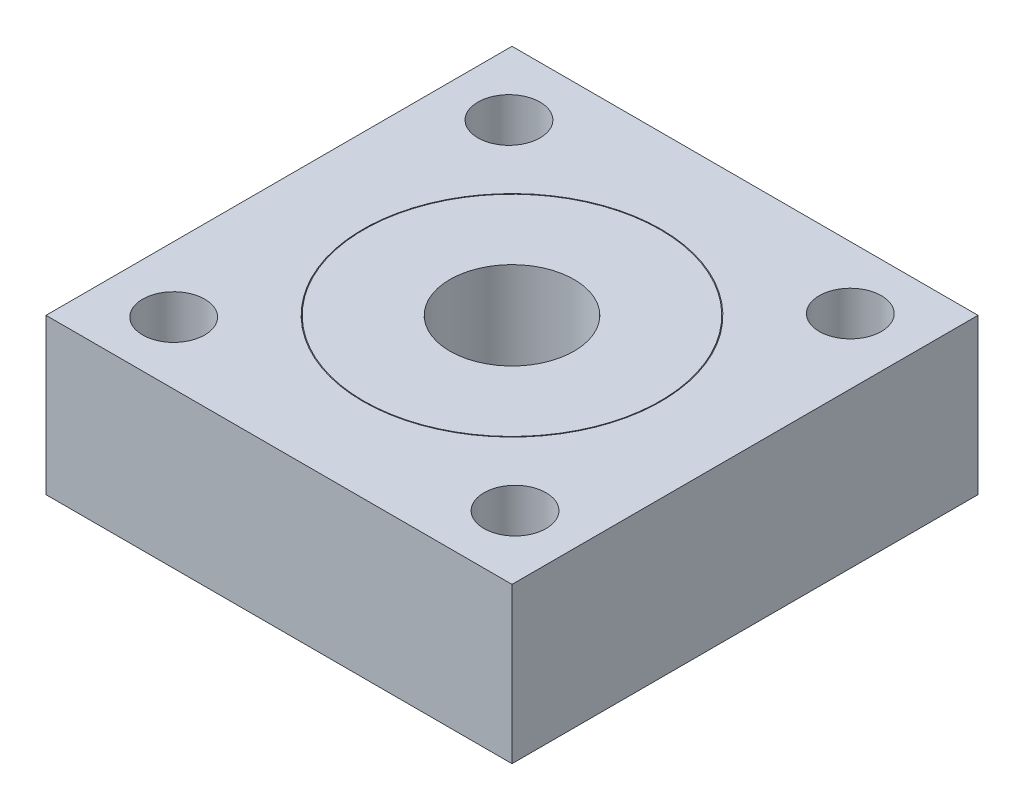
from build123d import *

# Parameters (mm, degrees)
SKETCH1_W           = 30
SKETCH1_H           = 30
BOSS_EXTRUDE1_DEPTH = 10
SKETCH2_R           = 9.6
SKETCH2_R_2         = 9.55
CUT_EXTRUDE1_DEPTH  = 7
SKETCH3_R           = 4
CUT_EXTRUDE2_DEPTH  = 7
SKETCH4_R           = 2
CUT_EXTRUDE3_DEPTH  = 10
CIRPATTERN1_COUNT   = 4


with BuildPart() as part:
    # Sketch1 → Boss-Extrude1 (new body)
    with BuildSketch(Plane(origin=(0, 0, 0), x_dir=(1, 0, 0), z_dir=(0, 1, 0))):
        Rectangle(SKETCH1_W, SKETCH1_H)
    extrude(amount=BOSS_EXTRUDE1_DEPTH)

    # Sketch2 → Cut-Extrude1 (cut)
    with BuildSketch(Plane(origin=(0, 10, 0), x_dir=(1, 0, 0), z_dir=(0, 1, 0))):
        Circle(SKETCH2_R)
        Circle(SKETCH2_R_2, mode=Mode.SUBTRACT)
    extrude(amount=-CUT_EXTRUDE1_DEPTH, mode=Mode.SUBTRACT)

    # Sketch3 → Cut-Extrude2 (cut)
    with BuildSketch(Plane(origin=(0, 10, 0), x_dir=(1, 0, 0), z_dir=(0, 1, 0))):
        Circle(SKETCH3_R)
    extrude(amount=-CUT_EXTRUDE2_DEPTH, mode=Mode.SUBTRACT)

    # Sketch4 → Cut-Extrude3 (cut)
    with BuildSketch(Plane(origin=(0, 10, 0), x_dir=(1, 0, 0), z_dir=(0, 1, 0))):
        with Locations((10.792349727, 10.987509758)):
            Circle(SKETCH4_R)
    cut_extrude3 = extrude(amount=-CUT_EXTRUDE3_DEPTH, mode=Mode.SUBTRACT)

    # CirPattern1: Cut-Extrude3 ×4 about axis
    cirpattern1_axis = Axis((0, 0, 0), (0, 1, 0))
    for i in range(1, CIRPATTERN1_COUNT):
        add(cut_extrude3.rotate(cirpattern1_axis, i * 360 / CIRPATTERN1_COUNT), mode=Mode.SUBTRACT)


solid = part.part
